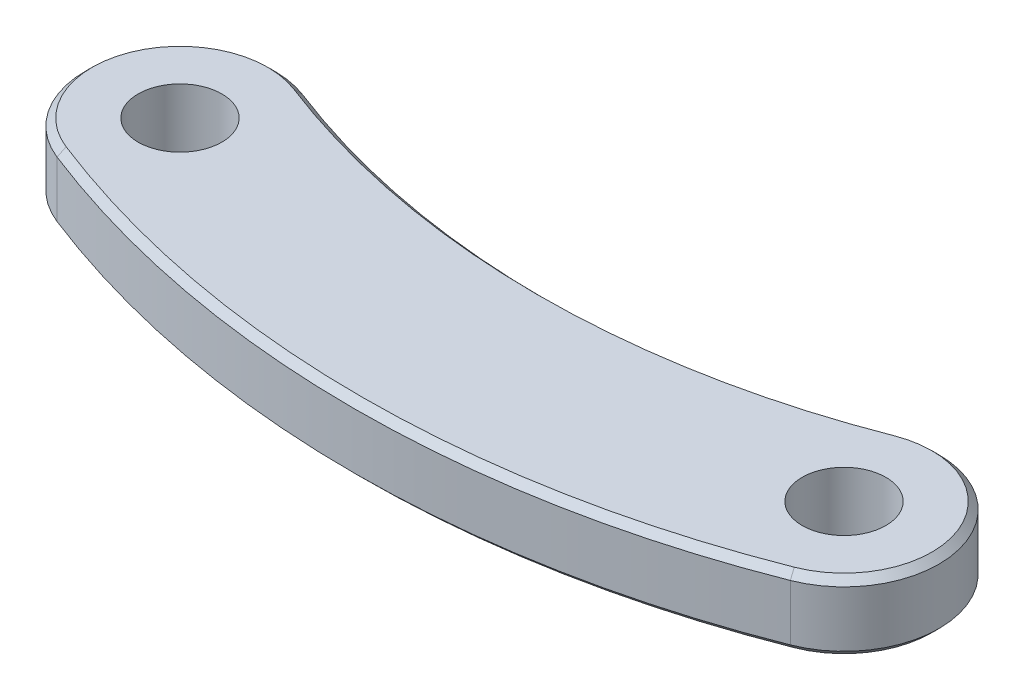
from build123d import *

# Parameters (mm, degrees)
SKETCH_1_R      = 3
EXTRUDE_1_DEPTH = 5
CHAMFER_1_SIZE  = 0.5


with BuildPart() as part:
    # 草图1 → 凸台-拉伸1 (new body)
    with BuildSketch(Plane(origin=(0, 0, 0), x_dir=(1, 0, 0), z_dir=(0, 1, 0))):
        with BuildLine():
            ThreePointArc((45.140425532, 6.339597261), (53.935193412, 2.470895471), (50.082208589, -6.330769347))
            ThreePointArc((50.082208589, -6.330769347), (23.8, -11.299093911), (-2.482208589, -6.330769347))
            ThreePointArc((-2.482208589, -6.330769347), (-6.335193412, 2.470895471), (2.459574468, 6.339597261))
            ThreePointArc((2.459574468, 6.339597261), (23.8, 2.344926441), (45.140425532, 6.339597261))
        make_face()
        Circle(SKETCH_1_R, mode=Mode.SUBTRACT)
        with Locations((47.6, 0)):
            Circle(SKETCH_1_R, mode=Mode.SUBTRACT)
    extrude(amount=EXTRUDE_1_DEPTH)

    # 倒角1
    chamfer_1_edges = [part.edges().sort_by_distance(p)[0] for p in [
        (23.8, 5, 11.299093911),
        (53.935193412, 5, -2.470895471),
        (23.8, 5, -2.344926441),
        (53.935193412, 0, -2.470895471),
        (23.8, 0, 11.299093911),
        (-6.335193412, 0, -2.470895471),
        (23.8, 0, -2.344926441),
        (-6.335193412, 5, -2.470895471),
    ]]
    chamfer(chamfer_1_edges, length=CHAMFER_1_SIZE)


solid = part.part
